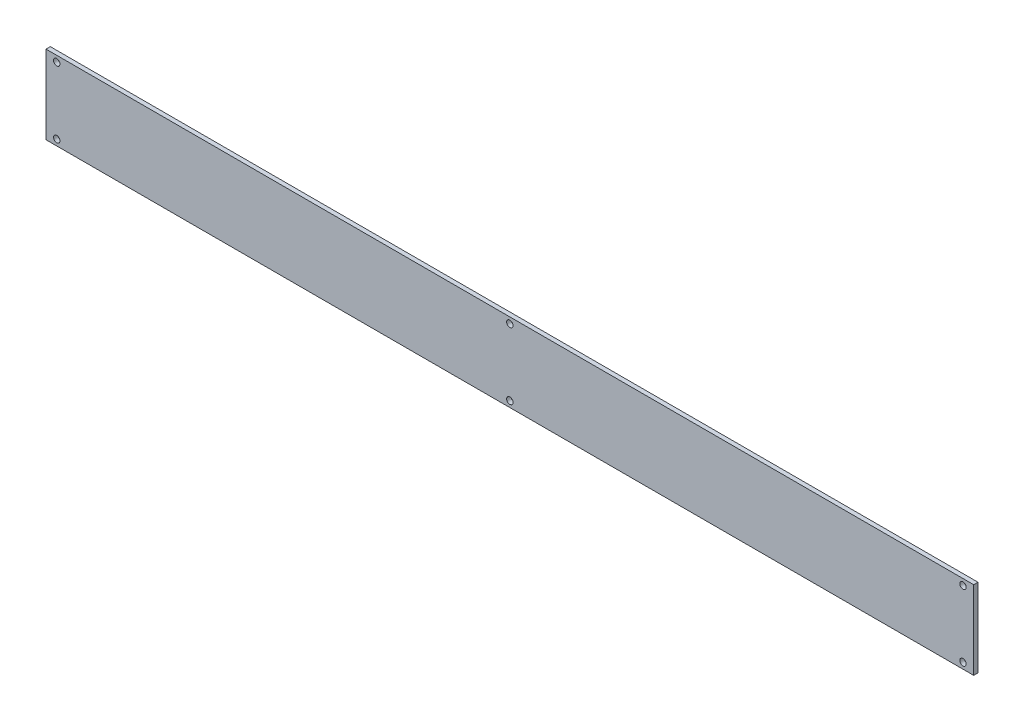
from build123d import *

# Parameters (mm, degrees)
SKETCH1_W           = 216.04
SKETCH1_H           = 6.355
SKETCH1_H_2         = 2.79
SKETCH1_R           = 0.75
BOSS_EXTRUDE1_DEPTH = 1


with BuildPart() as part:
    # Sketch1 → Boss-Extrude1 (new body)
    with BuildSketch(Plane.XY):
        with Locations((-116.651138015, 12.079424939)):
            Rectangle(SKETCH1_W, SKETCH1_H)
        with Locations((-116.651138015, 16.651924939)):
            Rectangle(SKETCH1_W, SKETCH1_H_2)
        with Locations((-222.171138015, 16.651924939)):
            Circle(SKETCH1_R, mode=Mode.SUBTRACT)
        with Locations((-116.651138015, 16.651924939)):
            Circle(SKETCH1_R, mode=Mode.SUBTRACT)
        with Locations((-11.131138015, 16.651924939)):
            Circle(SKETCH1_R, mode=Mode.SUBTRACT)
        with Locations((-116.651138015, 5.724424939)):
            Rectangle(SKETCH1_W, SKETCH1_H)
        with Locations((-116.651138015, 1.151924939)):
            Rectangle(SKETCH1_W, SKETCH1_H_2)
        with Locations((-222.171138015, 1.151924939)):
            Circle(SKETCH1_R, mode=Mode.SUBTRACT)
        with Locations((-116.651138015, 1.151924939)):
            Circle(SKETCH1_R, mode=Mode.SUBTRACT)
        with Locations((-11.131138015, 1.151924939)):
            Circle(SKETCH1_R, mode=Mode.SUBTRACT)
    extrude(amount=BOSS_EXTRUDE1_DEPTH)


solid = part.part
